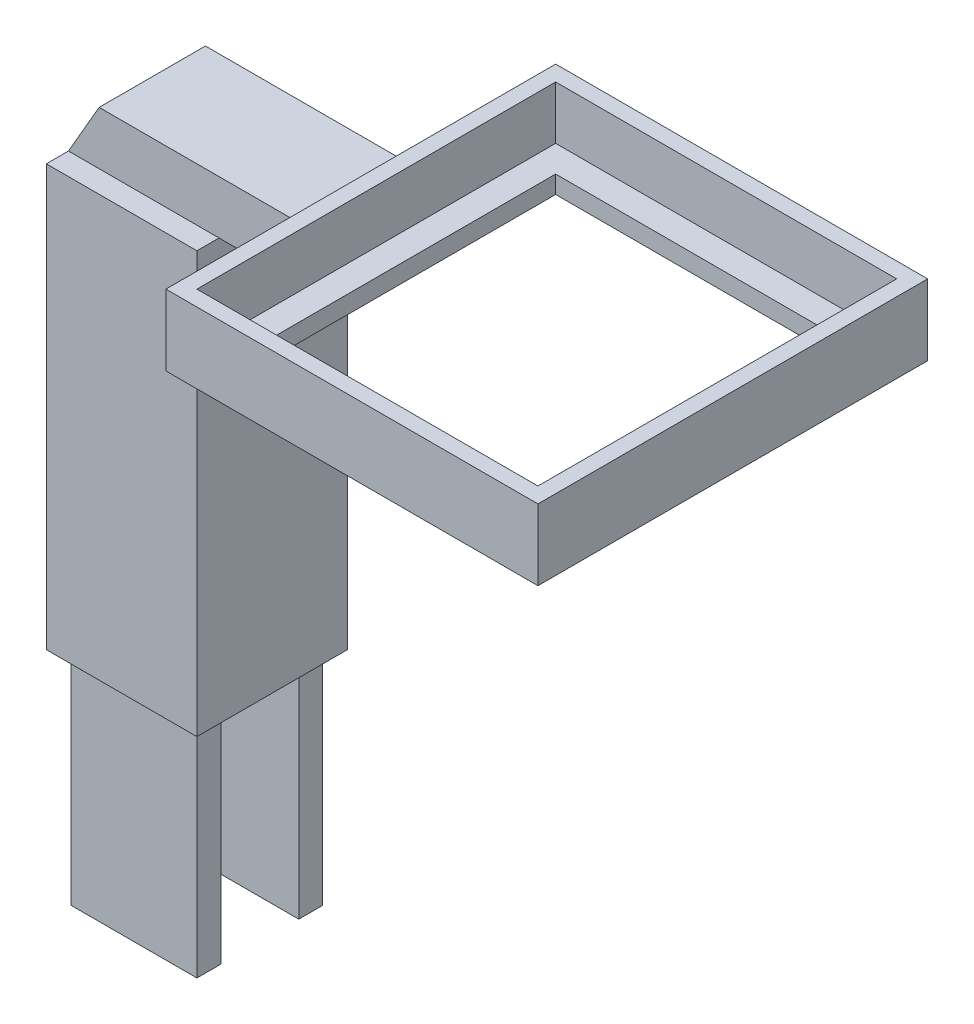
from build123d import *

# Parameters (mm, degrees)
SKETCH1_W                = 14.2
SKETCH1_H                = 2.7
BOSS_EXTRUDE1_DEPTH      = 25
BOSS_EXTRUDE1_2_DEPTH    = 25
SKETCH2_W                = 17
SKETCH2_H                = 17
BOSS_EXTRUDE2_DEPTH      = 47.5
BOSS_EXTRUDE4_DEPTH      = 6
SKETCH6_W                = 42
SKETCH6_H                = 44
SKETCH6_W_2              = 38.5
SKETCH6_H_2              = 40.5
BOSS_EXTRUDE5_DEPTH      = 2
BOSS_EXTRUDE5_DEPTH_BACK = 6
SKETCH7_W                = 38.5
SKETCH7_H                = 40.5
SKETCH7_W_2              = 32.5
SKETCH7_H_2              = 34.5
BOSS_EXTRUDE6_DEPTH      = 2
BOSS_EXTRUDE7_DEPTH      = 3.25


with BuildPart() as part:
    # Sketch1 → Boss-Extrude1 (new body)
    with BuildSketch(Plane(origin=(0, 0, 0), x_dir=(1, 0, 0), z_dir=(0, 1, 0))):
        with Locations((0, -5.75)):
            Rectangle(SKETCH1_W, SKETCH1_H)
    extrude(amount=BOSS_EXTRUDE1_DEPTH)



with BuildPart() as body_2:
    # Sketch1 → Boss-Extrude1 2 (new body)
    with BuildSketch(Plane(origin=(0, 0, 0), x_dir=(1, 0, 0), z_dir=(0, 1, 0))):
        with Locations((0, 5.75)):
            Rectangle(SKETCH1_W, SKETCH1_H)
    extrude(amount=BOSS_EXTRUDE1_2_DEPTH)


with BuildPart() as part_1:
    add(part.part)

    add(body_2.part)  # Boss-Extrude2 merges body 2
    # Sketch2 → Boss-Extrude2 (add)
    with BuildSketch(Plane(origin=(0, 25, 0), x_dir=(1, 0, 0), z_dir=(0, 1, 0))):
        Rectangle(SKETCH2_W, SKETCH2_H)
    extrude(amount=BOSS_EXTRUDE2_DEPTH)

    # Sketch5 → Boss-Extrude4 (add, symmetric)
    with BuildSketch(Plane.XY):
        Polygon((-8.5, 72.5), (-5.035898385, 78.5), (18.5, 78.5), (18.5, 72.5), align=None)
    extrude(amount=BOSS_EXTRUDE4_DEPTH, both=True)

    # Sketch6 → Boss-Extrude5 (add, two sides)
    with BuildSketch(Plane(origin=(0, 78.5, 0), x_dir=(1, 0, 0), z_dir=(0, 1, 0))) as boss_extrude5_sk:
        with Locations((39.5, 0)):
            Rectangle(SKETCH6_W, SKETCH6_H)
        with Locations((39.5, 0)):
            Rectangle(SKETCH6_W_2, SKETCH6_H_2, mode=Mode.SUBTRACT)
    extrude(amount=BOSS_EXTRUDE5_DEPTH)
    extrude(boss_extrude5_sk.sketch, amount=-BOSS_EXTRUDE5_DEPTH_BACK)

    # Sketch7 → Boss-Extrude6 (add)
    with BuildSketch(Plane.XZ.offset(-72.5)):
        with Locations((39.5, 0)):
            Rectangle(SKETCH7_W, SKETCH7_H)
        with Locations((39.5, 0)):
            Rectangle(SKETCH7_W_2, SKETCH7_H_2, mode=Mode.SUBTRACT)
    extrude(amount=-BOSS_EXTRUDE6_DEPTH)

    # Sketch8 → Boss-Extrude7 (add, symmetric)
    with BuildSketch(Plane.XY):
        Polygon((16, 72.5), (8.5, 59.509618943), (8.5, 72.5), align=None)
    extrude(amount=BOSS_EXTRUDE7_DEPTH, both=True)


solid = part_1.part
